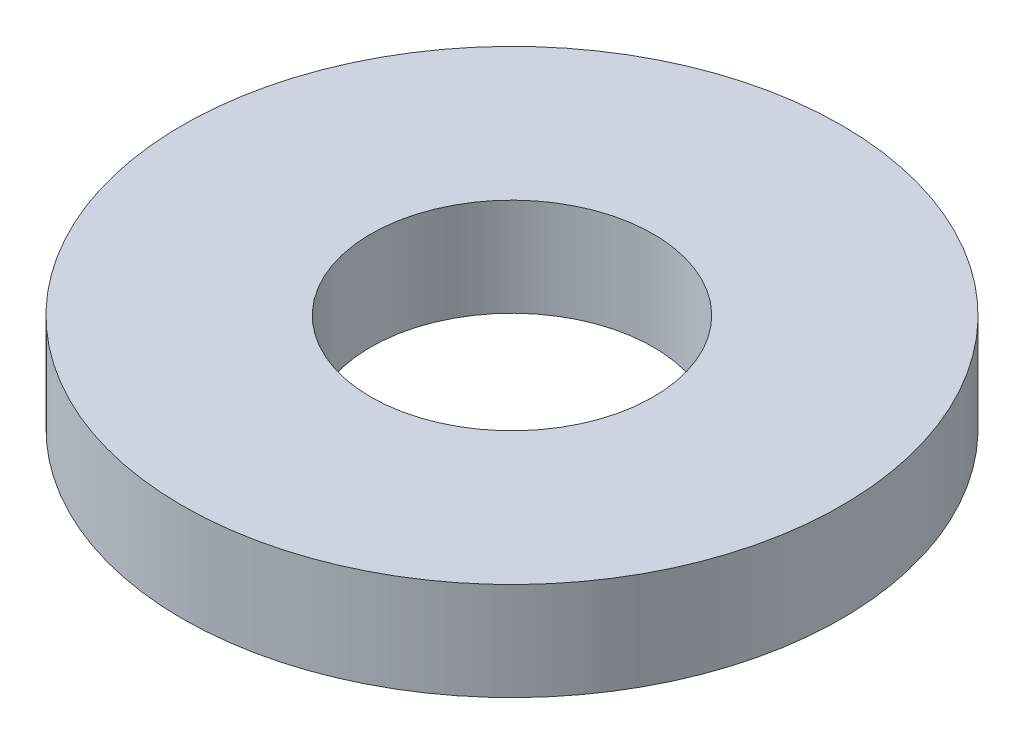
from build123d import *

# Parameters (mm, degrees)
SKETCH1_R           = 5.55625
BOSS_EXTRUDE1_DEPTH = 1.651
SKETCH5_R           = 2.38125
CUT_EXTRUDE1_DEPTH  = 2.651


with BuildPart() as part:
    # Sketch1 → Boss-Extrude1 (new body)
    with BuildSketch(Plane(origin=(0, 0, 0), x_dir=(1, 0, 0), z_dir=(0, 1, 0))):
        Circle(SKETCH1_R)
    extrude(amount=BOSS_EXTRUDE1_DEPTH)

    # Sketch5 → Cut-Extrude1 (cut, through all)
    with BuildSketch(Plane(origin=(0, 1.651, 0), x_dir=(-1, 0, 0), z_dir=(0, 1, 0))):
        Circle(SKETCH5_R)
    extrude(amount=-CUT_EXTRUDE1_DEPTH, mode=Mode.SUBTRACT)


solid = part.part
